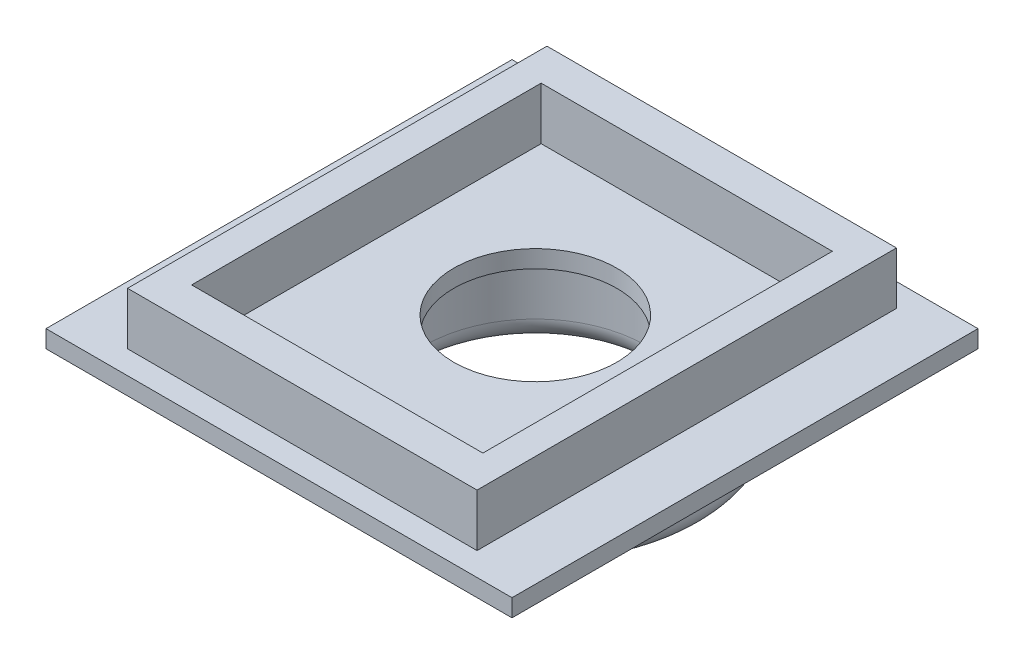
from build123d import *

# Parameters (mm, degrees)
CROQUIS1_W              = 40
CROQUIS1_H              = 40
SALIENTE_EXTRUIR1_DEPTH = 1.5
CROQUIS2_R              = 7
CORTAR_EXTRUIR1_DEPTH   = 1.5
CROQUIS3_W              = 30
CROQUIS3_H              = 36
CROQUIS3_W_2            = 25
CROQUIS3_H_2            = 30
SALIENTE_EXTRUIR2_DEPTH = 4.5
CROQUIS4_R              = 14.5
CROQUIS4_R_2            = 9.5
SALIENTE_EXTRUIR3_DEPTH = 7.5
REDONDEO1_R             = 2


with BuildPart() as part:
    # Croquis1 → Saliente-Extruir1 (new body)
    with BuildSketch(Plane(origin=(0, 0, 0), x_dir=(1, 0, 0), z_dir=(0, 1, 0))):
        Rectangle(CROQUIS1_W, CROQUIS1_H)
    extrude(amount=SALIENTE_EXTRUIR1_DEPTH)

    # Croquis2 → Cortar-Extruir1 (cut)
    with BuildSketch(Plane(origin=(0, 1.5, 0), x_dir=(1, 0, 0), z_dir=(0, 1, 0))):
        with Locations((0, 2)):
            Circle(CROQUIS2_R)
    extrude(amount=-CORTAR_EXTRUIR1_DEPTH, mode=Mode.SUBTRACT)

    # Croquis3 → Saliente-Extruir2 (add)
    with BuildSketch(Plane(origin=(0, 1.5, 0), x_dir=(1, 0, 0), z_dir=(0, 1, 0))):
        Rectangle(CROQUIS3_W, CROQUIS3_H)
        Rectangle(CROQUIS3_W_2, CROQUIS3_H_2, mode=Mode.SUBTRACT)
    extrude(amount=SALIENTE_EXTRUIR2_DEPTH)

    # Croquis4 → Saliente-Extruir3 (add)
    with BuildSketch(Plane.XZ):
        with Locations((0, -2)):
            Circle(CROQUIS4_R)
        with Locations((0, -2)):
            Circle(CROQUIS4_R_2, mode=Mode.SUBTRACT)
    extrude(amount=SALIENTE_EXTRUIR3_DEPTH)

    # Redondeo1
    redondeo1_edges = [part.edges().sort_by_distance(p)[0] for p in [
        (-14.5, -7.5, -2),
        (-9.5, -7.5, -2),
    ]]
    fillet(redondeo1_edges, radius=REDONDEO1_R)


solid = part.part
